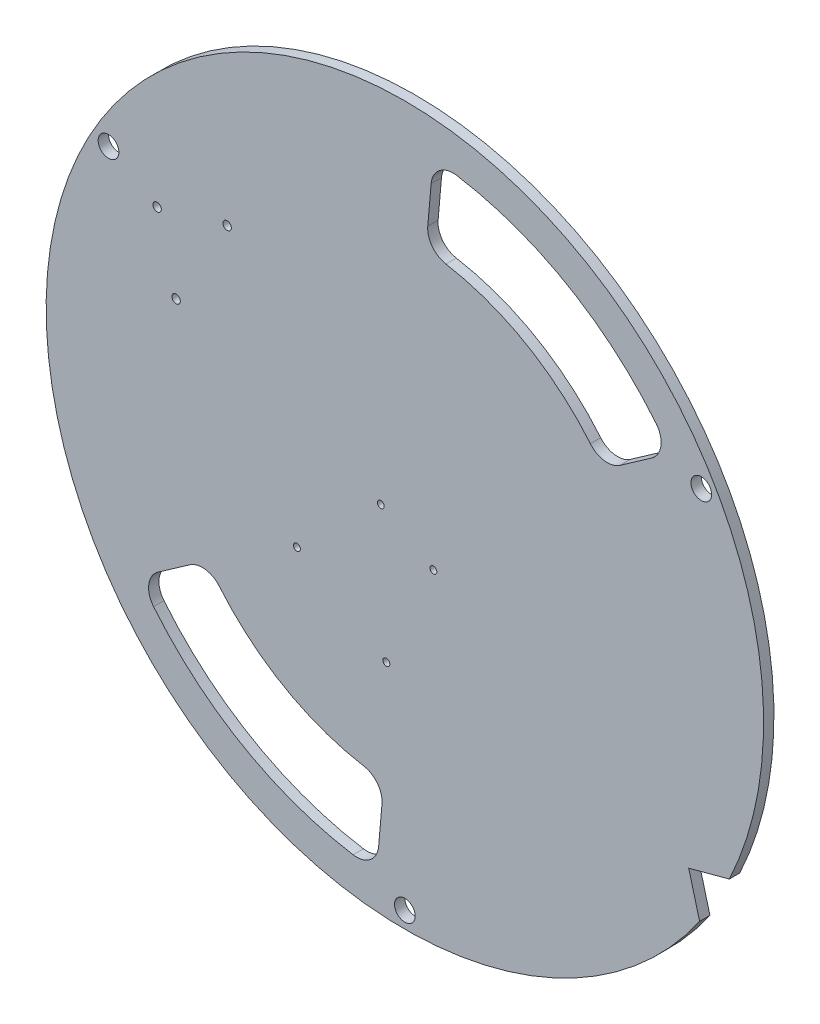
from build123d import *

# Parameters (mm, degrees)
SKETCH1_R                    = 4.7625
BOSS_EXTRUDE1_DEPTH          = 4.762
SKETCH5_R                    = 1.9304
MOTOR_MOUNTING_HOLES_DEPTH   = 5.762
SKETCH7_R                    = 1.5875
ARDUINO_MOUNTING_HOLES_DEPTH = 5.762
HANDLES_DEPTH                = 5.762


with BuildPart() as part:
    # Sketch1 → Boss-Extrude1 (new body)
    with BuildSketch(Plane.XY):
        with BuildLine():
            Line((135.64320405, -94.121895407), (130.632187999, -75.420528906))
            Line((130.632187999, -75.420528906), (149.3335545, -70.409512855))
            ThreePointArc((149.3335545, -70.409512855), (-45.751779591, 158.634122005), (-88.90313596, -139.119525648))
            ThreePointArc((-88.90313596, -139.119525648), (-82.55, -142.980794165), (-76.029475394, -146.552137041))
            ThreePointArc((-76.029475394, -146.552137041), (39.694857608, -160.257069359), (135.64320405, -94.121895407))
        make_face()
        with Locations((0, -157.49999996)):
            Circle(SKETCH1_R, mode=Mode.SUBTRACT)
        with Locations((-136.399001061, 78.74999998)):
            Circle(SKETCH1_R, mode=Mode.SUBTRACT)
        with Locations((136.399001061, 78.74999998)):
            Circle(SKETCH1_R, mode=Mode.SUBTRACT)
    extrude(amount=BOSS_EXTRUDE1_DEPTH)

    # Sketch5 → motor_mounting_holes (cut, through all)
    with BuildSketch(Plane.XY.offset(4.762)):
        with Locations((-114.020939706, 65.753939357)):
            Circle(SKETCH5_R)
        with Locations((-81.776804288, 74.490196087)):
            Circle(SKETCH5_R)
        with Locations((-105.284682976, 33.50980394)):
            Circle(SKETCH5_R)
    extrude(amount=-MOTOR_MOUNTING_HOLES_DEPTH, mode=Mode.SUBTRACT)

    # Sketch7 → arduino mounting holes (cut, through all)
    with BuildSketch(Plane(origin=(0, 0, 0), x_dir=(-1, 0, 0), z_dir=(0, 0, -1))):
        with Locations((-13.114276913, -15.277418882)):
            Circle(SKETCH7_R)
        with Locations((8.521314036, -62.911361657)):
            Circle(SKETCH7_R)
        with Locations((11.082472869, -1.307418882)):
            Circle(SKETCH7_R)
        with Locations((49.680700023, -37.681509395)):
            Circle(SKETCH7_R)
    extrude(amount=-ARDUINO_MOUNTING_HOLES_DEPTH, mode=Mode.SUBTRACT)

    # Sketch8 → handles (cut, through all)
    with BuildSketch(Plane.XY.offset(4.762)):
        with BuildLine():
            Line((12.087922967, 138.165591749), (10.53352986, 120.398797227))
            ThreePointArc((10.53352986, 120.398797227), (12.604919715, 113.314590764), (18.92461727, 109.501709969))
            ThreePointArc((18.92461727, 109.501709969), (55.5625, 96.237072996), (85.368953956, 71.140054298))
            ThreePointArc((85.368953956, 71.140054298), (91.830854363, 67.573476067), (99.001652054, 69.321703063))
            Line((99.001652054, 69.321703063), (113.6109509, 79.551244243))
            ThreePointArc((113.6109509, 79.551244243), (117.84686521, 86.476490147), (115.658001653, 94.293834786))
            ThreePointArc((115.658001653, 94.293834786), (74.6125, 129.23264088), (23.831855518, 147.309684975))
            ThreePointArc((23.831855518, 147.309684975), (15.967404692, 145.296624102), (12.087922967, 138.165591749))
        make_face()
        with BuildLine():
            Line((-113.6109509, -79.551244243), (-99.001652054, -69.321703063))
            ThreePointArc((-99.001652054, -69.321703063), (-91.830854363, -67.573476067), (-85.368953956, -71.140054298))
            ThreePointArc((-85.368953956, -71.140054298), (-55.5625, -96.237072996), (-18.92461727, -109.501709969))
            ThreePointArc((-18.92461727, -109.501709969), (-12.604919715, -113.314590764), (-10.53352986, -120.398797227))
            Line((-10.53352986, -120.398797227), (-12.087922967, -138.165591749))
            ThreePointArc((-12.087922967, -138.165591749), (-15.967404692, -145.296624102), (-23.831855518, -147.309684975))
            ThreePointArc((-23.831855518, -147.309684975), (-74.6125, -129.23264088), (-115.658001653, -94.293834786))
            ThreePointArc((-115.658001653, -94.293834786), (-117.84686521, -86.476490147), (-113.6109509, -79.551244243))
        make_face()
    extrude(amount=-HANDLES_DEPTH, mode=Mode.SUBTRACT)


solid = part.part
